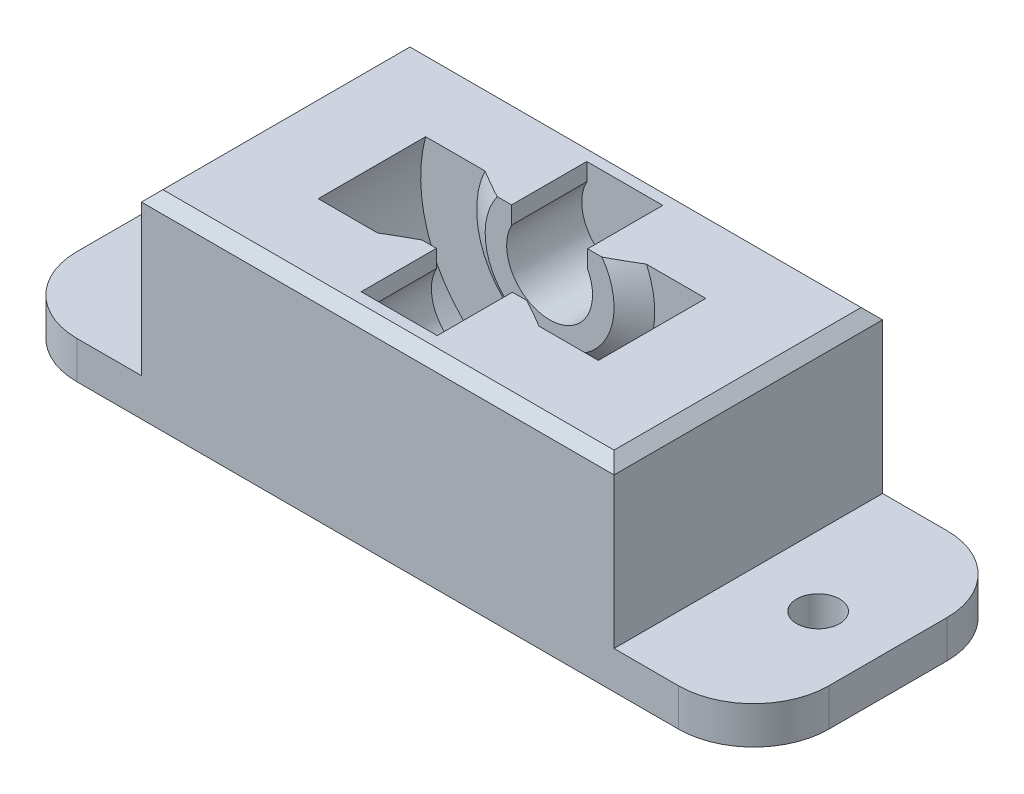
from build123d import *

# Parameters (mm, degrees)
BOSS_EXTRUDE1_DEPTH = 12.5
BOSS_EXTRUDE2_DEPTH = 7.5
BOSS_EXTRUDE3_DEPTH = 7.5
SKETCH5_W           = 70
SKETCH5_H           = 25
CUT_EXTRUDE1_DEPTH  = 10
CUT_EXTRUDE2_START  = -1.632728
SKETCH6_W           = 7.078863834
SKETCH6_H           = 10
CUT_EXTRUDE2_DEPTH  = 1.632728
BOSS_EXTRUDE4_DEPTH = 2
FILLET1_R           = 7
SKETCH8_R           = 2
CUT_EXTRUDE3_DEPTH  = 40
CHAMFER1_SIZE       = 1


with BuildPart() as part:
    # Sketch1 → Boss-Extrude1 (new, symmetric)
    with BuildSketch(Plane.XY):
        with BuildLine():
            Line((22, 2.58125), (22, -7.41875))
            Line((22, -7.41875), (35, -7.41875))
            Line((35, -7.41875), (35, -10.91875))
            Line((35, -10.91875), (22, -10.91875))
            Line((22, -10.91875), (-22, -10.91875))
            Line((-22, -10.91875), (-35, -10.91875))
            Line((-35, -10.91875), (-35, -7.41875))
            Line((-35, -7.41875), (-22, -7.41875))
            Line((-22, -7.41875), (-22, 2.58125))
            Line((-22, 2.58125), (-22, 7.577421516))
            Line((-22, 7.577421516), (-13.039431917, 7.577421516))
            ThreePointArc((-13.039431917, 7.577421516), (0, -9.41875), (13.039431917, 7.577421516))
            Line((13.039431917, 7.577421516), (22, 7.577421516))
            Line((22, 7.577421516), (22, 2.58125))
        make_face()
    extrude(amount=BOSS_EXTRUDE1_DEPTH, both=True)

    # Sketch2 → Boss-Extrude2 (add)
    with BuildSketch(Plane.XY.offset(5)):
        with BuildLine():
            Line((-3.539431917, 5.944693506), (-3.539431917, 7.577421516))
            Line((-3.539431917, 7.577421516), (-13.039431917, 7.577421516))
            ThreePointArc((-13.039431917, 7.577421516), (0, -9.41875), (13.039431917, 7.577421516))
            Line((13.039431917, 7.577421516), (3.539431917, 7.577421516))
            Line((3.539431917, 7.577421516), (3.539431917, 5.944693506))
            ThreePointArc((3.539431917, 5.944693506), (0, 0.08125), (-3.539431917, 5.944693506))
        make_face()
    extrude(amount=BOSS_EXTRUDE2_DEPTH)

    # Sketch3 → Boss-Extrude3 (add)
    with BuildSketch(Plane.XY.offset(-5)):
        with BuildLine():
            Line((3.539431917, 7.577421516), (3.539431917, 5.944693506))
            ThreePointArc((3.539431917, 5.944693506), (0, 0.08125), (-3.539431917, 5.944693506))
            Line((-3.539431917, 5.944693506), (-3.539431917, 7.577421516))
            Line((-3.539431917, 7.577421516), (-13.039431917, 7.577421516))
            ThreePointArc((-13.039431917, 7.577421516), (0, -9.41875), (13.039431917, 7.577421516))
            Line((13.039431917, 7.577421516), (3.539431917, 7.577421516))
        make_face()
    extrude(amount=-BOSS_EXTRUDE3_DEPTH)

    # Sketch4 → Revolve1 (revolve)
    with BuildSketch(Plane(origin=(0, 4.08125, 0), x_dir=(1, 0, 0), z_dir=(0, 1, 0)), mode=Mode.PRIVATE) as revolve1_sk:
        Polygon((-4, -5), (-4, -3.5), (-6, -3.5), (-8.289431917, -5), align=None)
        Polygon((-4, 5), (-4, 3.5), (-6, 3.5), (-8.289431917, 5), align=None)
    revolve(revolve1_sk.sketch.rotate(Axis((0, 4.08125, 0), (0, 0, -1)), 27.765950742), axis=Axis((0, 4.08125, 0), (0, 0, -1)))

    # Sketch5 → Cut-Extrude1 (cut)
    with BuildSketch(Plane(origin=(0, 7.577421516, 0), x_dir=(1, 0, 0), z_dir=(0, 1, 0))):
        Rectangle(SKETCH5_W, SKETCH5_H)
    extrude(amount=CUT_EXTRUDE1_DEPTH, mode=Mode.SUBTRACT)

    # Sketch6 → Cut-Extrude2 (cut)
    with BuildSketch(Plane(origin=(0, 7.577421516, 0), x_dir=(1, 0, 0), z_dir=(0, 1, 0)).offset(CUT_EXTRUDE2_START)):
        Rectangle(SKETCH6_W, SKETCH6_H)
    extrude(amount=CUT_EXTRUDE2_DEPTH, mode=Mode.SUBTRACT)

    # Sketch7 → Boss-Extrude4 (add)
    with BuildSketch(Plane.XY.offset(12.5)):
        Polygon((-22, 2.38125), (-22, 7.577421516), (22, 7.577421516), (22, -3.038829349), (22, -10.91875), (-22, -10.91875), align=None)
    boss_extrude4 = extrude(amount=-BOSS_EXTRUDE4_DEPTH)

    # Mirror1: Boss-Extrude4 across plane
    add(boss_extrude4.mirror(Plane.XY))

    # Fillet1
    fillet1_edges = [part.edges().sort_by_distance(p)[0] for p in [
        (35, -9.16875, -12.5),
        (-35, -9.16875, -12.5),
        (-35, -9.16875, 12.5),
        (35, -9.16875, 12.5),
    ]]
    fillet(fillet1_edges, radius=FILLET1_R)

    # Sketch8 → Cut-Extrude3 (cut)
    with BuildSketch(Plane(origin=(0, -7.41875, 0), x_dir=(1, 0, 0), z_dir=(0, 1, 0))):
        with Locations(Location((28.5, 0, 0), (0, 0, 180))):
            Circle(SKETCH8_R)
        with Locations(Location((-28.5, 0, 0), (0, 0, 180))):
            Circle(SKETCH8_R)
    extrude(amount=-CUT_EXTRUDE3_DEPTH, mode=Mode.SUBTRACT)

    # Chamfer1
    chamfer1_edges = [part.edges().sort_by_distance(p)[0] for p in [
        (0, 7.577421516, -12.5),
        (22, 7.577421516, 0),
        (-22, 7.577421516, 0),
        (0, 7.577421516, 12.5),
    ]]
    chamfer(chamfer1_edges, length=CHAMFER1_SIZE)


solid = part.part
